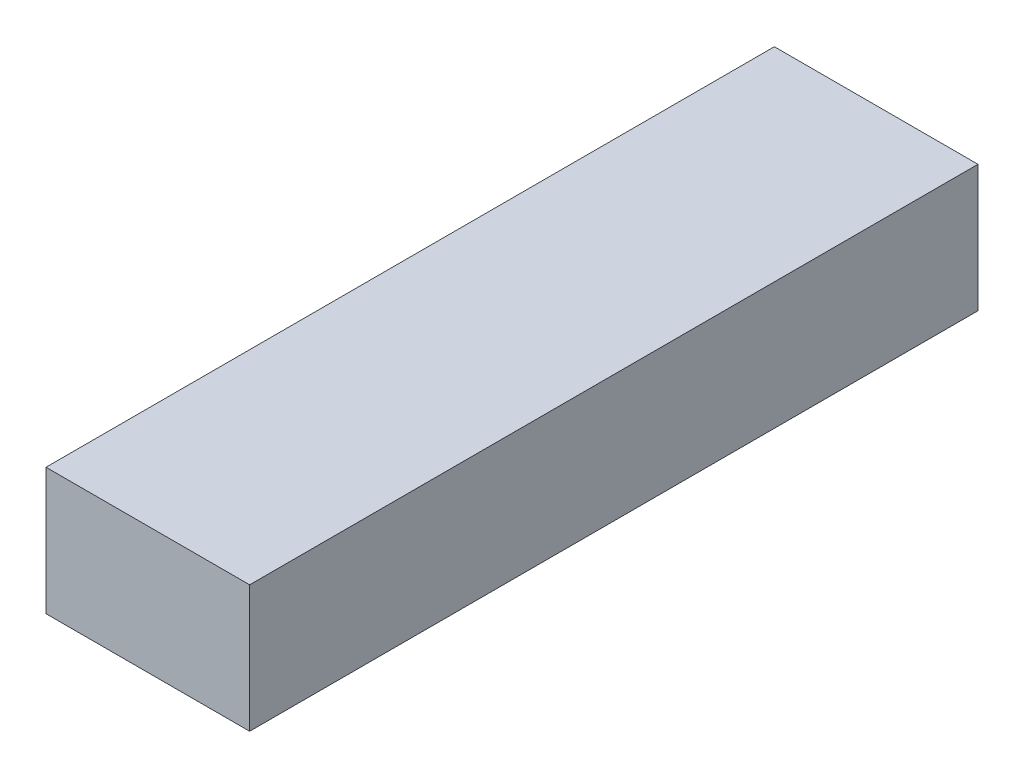
from build123d import *

# Parameters (mm, degrees)
SKETCH_1_W      = 33.55
SKETCH_1_H      = 20.9
EXTRUDE_1_DEPTH = 120


with BuildPart() as part:
    # 스케치1 → 보스-돌출1 (new body)
    with BuildSketch(Plane.XY):
        with Locations((-26.57919302, -57.199975)):
            Rectangle(SKETCH_1_W, SKETCH_1_H)
    extrude(amount=EXTRUDE_1_DEPTH)


solid = part.part
